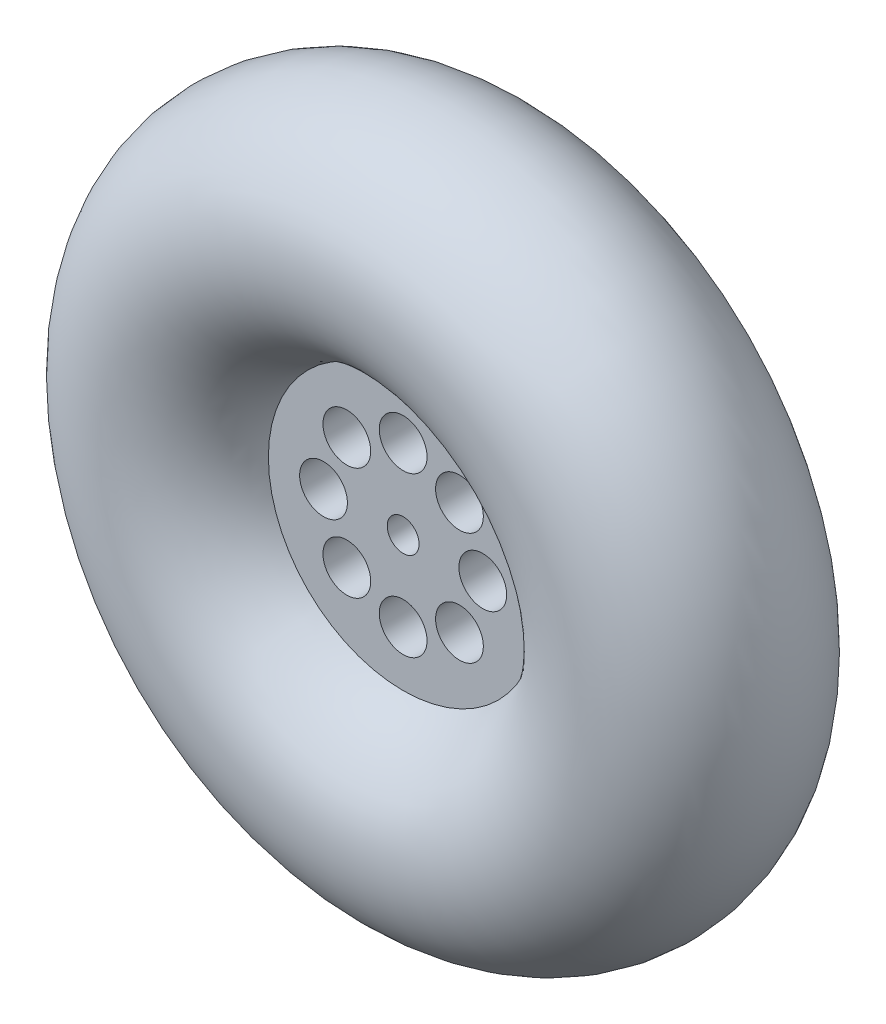
from build123d import *

# Parameters (mm, degrees)
SKETCH_1_R          = 14
SKETCH_2_R          = 18
SKETCH_2_R_2        = 2
EXTRUDE_2_DEPTH     = 5
SKETCH_3_R          = 3
CUT_EXTRUDE_1_DEPTH = 20


with BuildPart() as part:
    # 草图1 → 旋转1 (revolve)
    with BuildSketch(Plane(origin=(0, 0, 0), x_dir=(0, 0, -1), z_dir=(1, 0, 0))):
        with Locations((0, 30)):
            Circle(SKETCH_1_R)
    revolve(axis=Axis((0, 0, 15.4), (0, 0, -1)))

    # 草图2 → 凸台-拉伸2 (add, symmetric)
    with BuildSketch(Plane.XY):
        Circle(SKETCH_2_R)
        Circle(SKETCH_2_R_2, mode=Mode.SUBTRACT)
    extrude(amount=EXTRUDE_2_DEPTH, both=True)

    # 草图3 → 切除-拉伸1 (cut, through all)
    with BuildSketch(Plane.XY.offset(5)):
        with Locations((0, 10)):
            Circle(SKETCH_3_R)
        with Locations((7.071067812, 7.071067812)):
            Circle(SKETCH_3_R)
        with Locations((10, 0)):
            Circle(SKETCH_3_R)
        with Locations((7.071067812, -7.071067812)):
            Circle(SKETCH_3_R)
        with Locations((0, -10)):
            Circle(SKETCH_3_R)
        with Locations((-7.071067812, -7.071067812)):
            Circle(SKETCH_3_R)
        with Locations((-10, 0)):
            Circle(SKETCH_3_R)
        with Locations((-7.071067812, 7.071067812)):
            Circle(SKETCH_3_R)
    extrude(amount=-CUT_EXTRUDE_1_DEPTH, mode=Mode.SUBTRACT)


solid = part.part
